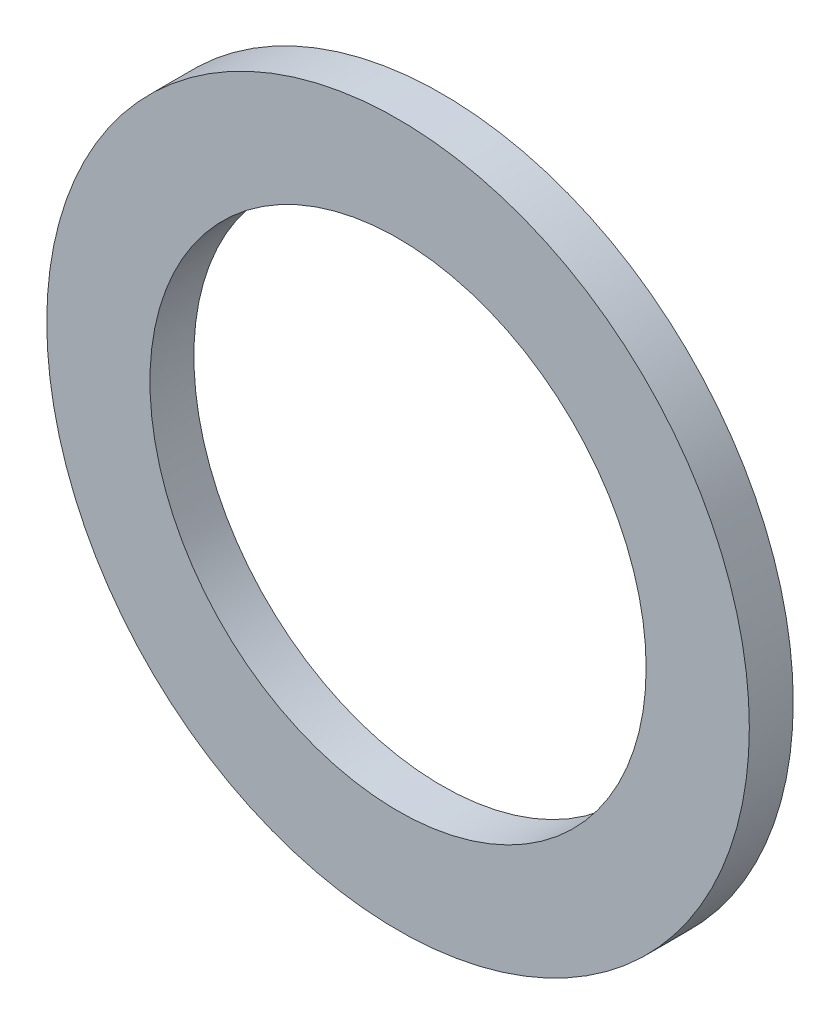
from build123d import *

# Parameters (mm, degrees)
SKETCH1_R          = 8
SKETCH1_R_2        = 5.65
BASE_EXTRUDE_DEPTH = 1


with BuildPart() as part:
    # Sketch1 → Base-Extrude (new body)
    with BuildSketch(Plane.XY):
        Circle(SKETCH1_R)
        Circle(SKETCH1_R_2, mode=Mode.SUBTRACT)
    extrude(amount=-BASE_EXTRUDE_DEPTH)


solid = part.part
